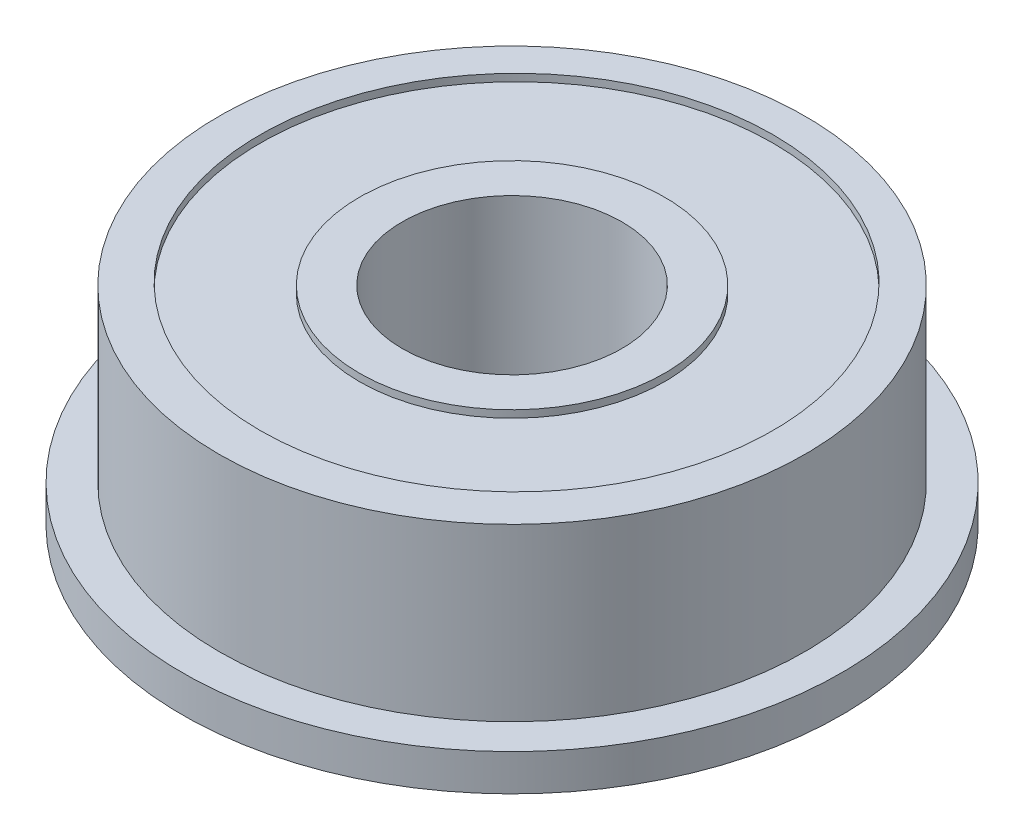
from build123d import *

# Parameters (mm, degrees)
SKETCH_1_R          = 12
SKETCH_1_R_2        = 4.5
EXTRUDE_1_DEPTH     = 7
SKETCH_2_R          = 13.5
SKETCH_2_R_2        = 4.5
EXTRUDE_2_DEPTH     = 1.5
SKETCH_3_R          = 10.5
SKETCH_3_R_2        = 6.25
CUT_EXTRUDE_1_DEPTH = 0.3
SKETCH_4_R          = 10.5
SKETCH_4_R_2        = 6.25
CUT_EXTRUDE_2_DEPTH = 0.3


with BuildPart() as part:
    # 草图1 → 凸台-拉伸1 (new body)
    with BuildSketch(Plane(origin=(0, 0, 0), x_dir=(1, 0, 0), z_dir=(0, 1, 0))):
        Circle(SKETCH_1_R)
        Circle(SKETCH_1_R_2, mode=Mode.SUBTRACT)
    extrude(amount=EXTRUDE_1_DEPTH)

    # 草图2 → 凸台-拉伸2 (add)
    with BuildSketch(Plane.XZ):
        Circle(SKETCH_2_R)
        Circle(SKETCH_2_R_2, mode=Mode.SUBTRACT)
    extrude(amount=EXTRUDE_2_DEPTH)

    # 草图3 → 切除-拉伸1 (cut)
    with BuildSketch(Plane(origin=(0, 7, 0), x_dir=(1, 0, 0), z_dir=(0, 1, 0))):
        with Locations((0, 0.185580925)):
            Circle(SKETCH_3_R)
        Circle(SKETCH_3_R_2, mode=Mode.SUBTRACT)
    extrude(amount=-CUT_EXTRUDE_1_DEPTH, mode=Mode.SUBTRACT)

    # 草图4 → 切除-拉伸2 (cut)
    with BuildSketch(Plane.XZ.offset(1.5)):
        Circle(SKETCH_4_R)
        Circle(SKETCH_4_R_2, mode=Mode.SUBTRACT)
    extrude(amount=-CUT_EXTRUDE_2_DEPTH, mode=Mode.SUBTRACT)


solid = part.part
